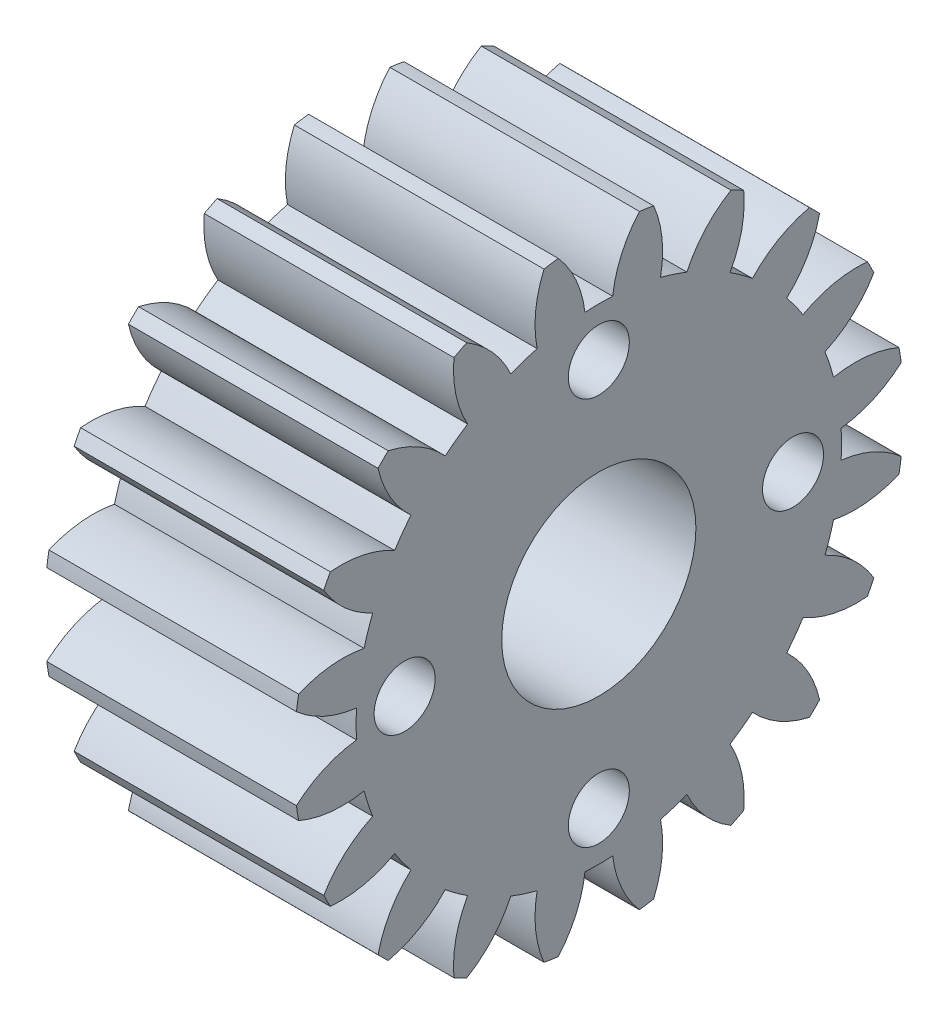
from build123d import *

# Parameters (mm, degrees)
BASPROSKE_W        = 9
BASPROSKE_H        = 11
TOOTHCUT_DEPTH     = 18.972200756
TEETHCUTS_COUNT    = 20
TEETHCUTS_ANGLE    = 342
BORSKE_R           = 3.5
BORE_DEPTH         = 50.0000508
SKETCH1_R          = 1.1
CUT_EXTRUDE1_DEPTH = 18.852389344


with BuildPart() as part:
    # BasProSke → Base-Revolve (revolve)
    with BuildSketch(Plane(origin=(0, 0, 0), x_dir=(1, 0, 0), z_dir=(0, 1, 0)), mode=Mode.PRIVATE) as base_revolve_sk:
        with Locations((4.5, 5.5)):
            Rectangle(BASPROSKE_W, BASPROSKE_H)
    revolve(base_revolve_sk.sketch.rotate(Axis((-10, 0, 0), (1, 0, 0)), 180), axis=Axis((-10, 0, 0), (1, 0, 0)))

    # TooCutSke → ToothCut (cut, through all)
    with BuildSketch(Plane(origin=(0, 0, 0), x_dir=(0, 0, -1), z_dir=(1, 0, 0))):
        with BuildLine():
            ThreePointArc((0.499924007, 8.734705318), (0, 8.749), (-0.499924007, 8.734705318))
            ThreePointArc((-0.499924007, 8.734705318), (-0.824302243, 9.905497836), (-1.485192705, 10.924909509))
            ThreePointArc((-1.485192705, 10.924909509), (0, 11.0254), (1.485192705, 10.924909509))
            ThreePointArc((1.485192705, 10.924909509), (0.824302243, 9.905497836), (0.499924007, 8.734705318))
        make_face()
    toothcut = extrude(amount=TOOTHCUT_DEPTH, mode=Mode.SUBTRACT)

    # TeethCuts: ToothCut ×20 about axis
    teethcuts_axis = Axis((-10, 0, 0), (1, 0, 0))
    for i in range(1, TEETHCUTS_COUNT):
        add(toothcut.rotate(teethcuts_axis, i * TEETHCUTS_ANGLE / (TEETHCUTS_COUNT - 1)), mode=Mode.SUBTRACT)

    # BorSke → Bore (cut, symmetric)
    with BuildSketch(Plane(origin=(0, 0, 0), x_dir=(0, 0, -1), z_dir=(1, 0, 0))):
        with Locations(Location((0, 0, 0), (0, 0, 180))):
            Circle(BORSKE_R)
    extrude(amount=BORE_DEPTH, both=True, mode=Mode.SUBTRACT)

    # Sketch1 → Cut-Extrude1 (cut, through all)
    with BuildSketch(Plane(origin=(9, 0, 0), x_dir=(0, 0, -1), z_dir=(1, 0, 0))):
        with Locations((0, -7)):
            Circle(SKETCH1_R)
        with Locations((0, 7)):
            Circle(SKETCH1_R)
        with Locations((7, 0)):
            Circle(SKETCH1_R)
        with Locations((-7, 0)):
            Circle(SKETCH1_R)
    extrude(amount=-CUT_EXTRUDE1_DEPTH, mode=Mode.SUBTRACT)


solid = part.part
